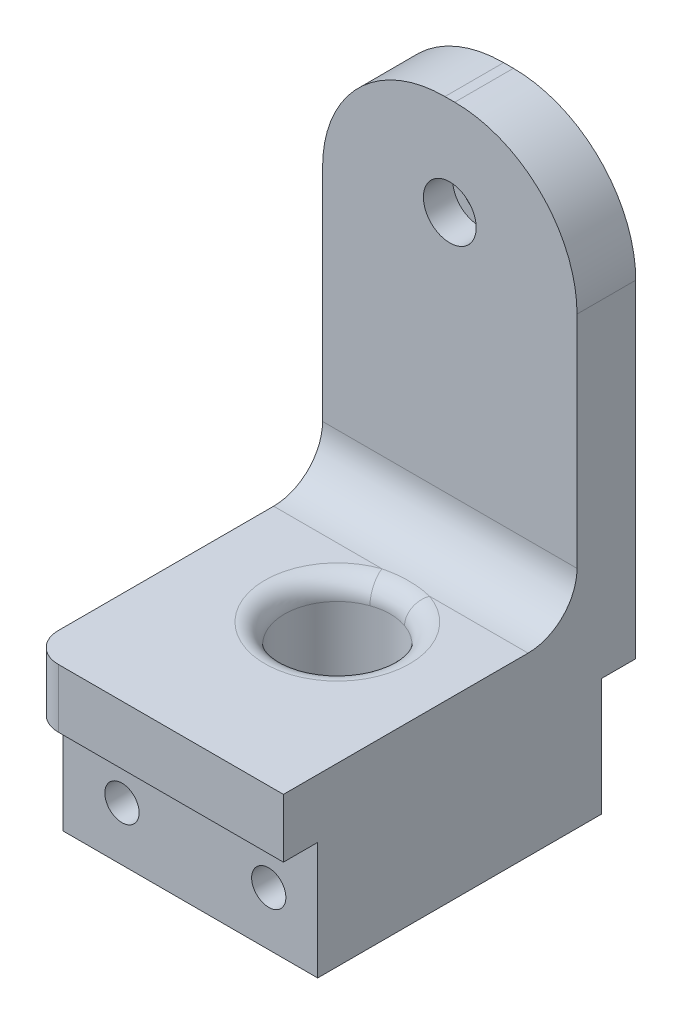
from build123d import *

# Parameters (mm, degrees)
BOSS_EXTRUDE1_DEPTH = 6
SKETCH2_W           = 26
SKETCH2_H           = 6
BOSS_EXTRUDE2_DEPTH = 40
FILLET1_R           = 12.5
SKETCH3_R           = 2.7
CUT_EXTRUDE1_DEPTH  = 7
SKETCH4_W           = 26
SKETCH4_H           = 29
BOSS_EXTRUDE3_DEPTH = 12
FILLET2_R           = 5
SKETCH5_R           = 1.75
CUT_EXTRUDE2_DEPTH  = 33.5
CUT_EXTRUDE3_DEPTH  = 41
CUT_EXTRUDE4_REACH  = 60
SKETCH7_R           = 5.4
FILLET3_R           = 2
SKETCH8_R           = 2.7
SKETCH8_R_2         = 1.6
BOSS_EXTRUDE4_DEPTH = 3


with BuildPart() as part:
    # Sketch1 → Boss-Extrude1 (new body)
    with BuildSketch(Plane(origin=(0, -44, 0), x_dir=(1, 0, 0), z_dir=(0, 1, 0))):
        with BuildLine():
            Line((50.264100782, -8), (50.264100782, 28))
            Line((50.264100782, 28), (27.264100782, 28))
            ThreePointArc((27.264100782, 28), (25.142780438, 27.121320344), (24.264100782, 25))
            Line((24.264100782, 25), (24.264100782, -5))
            ThreePointArc((24.264100782, -5), (25.142780438, -7.121320344), (27.264100782, -8))
            Line((27.264100782, -8), (50.264100782, -8))
        make_face()
    extrude(amount=BOSS_EXTRUDE1_DEPTH)

    # Sketch2 → Boss-Extrude2 (add)
    with BuildSketch(Plane(origin=(0, -38, 0), x_dir=(1, 0, 0), z_dir=(0, 1, 0))):
        with Locations((37.264100782, 25)):
            Rectangle(SKETCH2_W, SKETCH2_H)
    extrude(amount=BOSS_EXTRUDE2_DEPTH)

    # Fillet1
    fillet1_edges = [part.edges().sort_by_distance(p)[0] for p in [
        (50.264100782, 2, -25),
        (24.264100782, 2, -25),
    ]]
    fillet(fillet1_edges, radius=FILLET1_R)

    # Sketch3 → Cut-Extrude1 (cut, through all)
    with BuildSketch(Plane.XY.offset(-22)):
        with Locations((37.264100782, -8)):
            Circle(SKETCH3_R)
    extrude(amount=-CUT_EXTRUDE1_DEPTH, mode=Mode.SUBTRACT)

    # Sketch4 → Boss-Extrude3 (add)
    with BuildSketch(Plane.XZ.offset(44)):
        with Locations((37.264100782, -10)):
            Rectangle(SKETCH4_W, SKETCH4_H)
    extrude(amount=BOSS_EXTRUDE3_DEPTH)

    # Fillet2
    fillet2_edges = [part.edges().sort_by_distance(p)[0] for p in [
        (37.264100782, -38, -22),
    ]]
    fillet(fillet2_edges, radius=FILLET2_R)

    # Sketch5 → Cut-Extrude2 (cut, through all)
    with BuildSketch(Plane(origin=(0, 0, -24.5), x_dir=(-1, 0, 0), z_dir=(0, 0, -1))):
        with Locations((-45.264100782, -50.5)):
            Circle(SKETCH5_R)
        with Locations((-30.264100782, -50.5)):
            Circle(SKETCH5_R)
    extrude(amount=-CUT_EXTRUDE2_DEPTH, mode=Mode.SUBTRACT)

    # Sketch6 → Cut-Extrude3 (cut, through all)
    with BuildSketch(Plane.XZ.offset(38)):
        with BuildLine():
            Line((24.264100782, -28), (27.264100782, -28))
            ThreePointArc((27.264100782, -28), (25.142780438, -27.121320344), (24.264100782, -25))
            Line((24.264100782, -25), (24.264100782, -28))
        make_face()
    extrude(amount=-CUT_EXTRUDE3_DEPTH, mode=Mode.SUBTRACT)

    # Sketch7 → Cut-Extrude4 (cut, up to next)
    with BuildSketch(Plane.XZ.offset(56), mode=Mode.PRIVATE) as cut_extrude4_sk1:
        with Locations((37.764100782, -10.008379986)):
            Circle(SKETCH7_R)
    cut_extrude4_tool1 = extrude(cut_extrude4_sk1.sketch, amount=-CUT_EXTRUDE4_REACH, mode=Mode.PRIVATE) & part.part
    add(cut_extrude4_tool1.solids().sort_by_distance((37.764101, -56, -10.00838))[0], mode=Mode.SUBTRACT)

    # Fillet3
    fillet3_edges = [part.edges().sort_by_distance(p)[0] for p in [
        (32.364100782, -38, -10.008379986),
        (32.364100782, -56, -10.008379986),
    ]]
    fillet(fillet3_edges, radius=FILLET3_R)

    # Sketch8 → Boss-Extrude4 (add)
    with BuildSketch(Plane(origin=(0, 0, -28), x_dir=(-1, 0, 0), z_dir=(0, 0, -1))):
        with Locations((-37.264100782, -8)):
            Circle(SKETCH8_R)
        with Locations((-37.264100782, -8)):
            Circle(SKETCH8_R_2, mode=Mode.SUBTRACT)
    extrude(amount=-BOSS_EXTRUDE4_DEPTH)


solid = part.part
